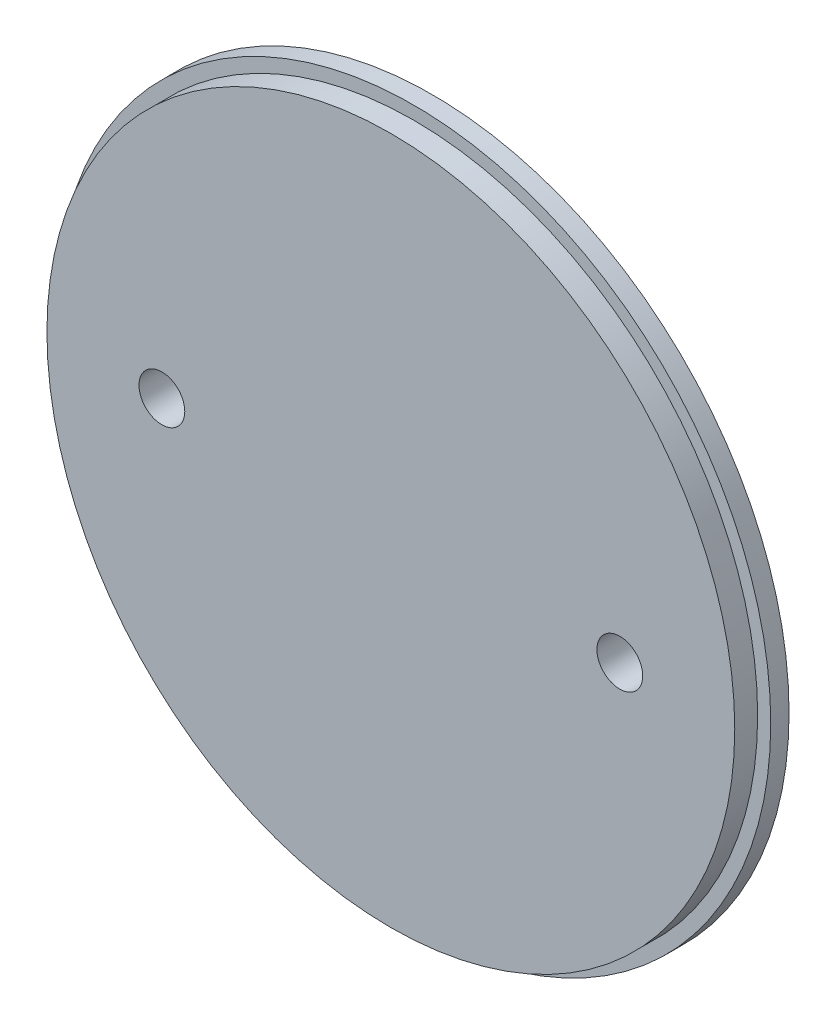
from build123d import *

# Parameters (mm, degrees)
SKETCH1_R           = 49.5046
BOSS_EXTRUDE1_DEPTH = 2.54
SKETCH2_R           = 47.6885
BOSS_EXTRUDE2_DEPTH = 3.175
SKETCH3_R           = 3.175
CUT_EXTRUDE1_DEPTH  = 6.715


with BuildPart() as part:
    # Sketch1 → Boss-Extrude1 (new body)
    with BuildSketch(Plane.XY):
        Circle(SKETCH1_R)
    extrude(amount=BOSS_EXTRUDE1_DEPTH)

    # Sketch2 → Boss-Extrude2 (add)
    with BuildSketch(Plane.XY.offset(2.54)):
        Circle(SKETCH2_R)
    extrude(amount=BOSS_EXTRUDE2_DEPTH)

    # Sketch3 → Cut-Extrude1 (cut, through all)
    with BuildSketch(Plane.XY.offset(5.715)):
        with Locations((-31.75, 0)):
            Circle(SKETCH3_R)
        with Locations((31.75, 0)):
            Circle(SKETCH3_R)
    extrude(amount=-CUT_EXTRUDE1_DEPTH, mode=Mode.SUBTRACT)


solid = part.part
